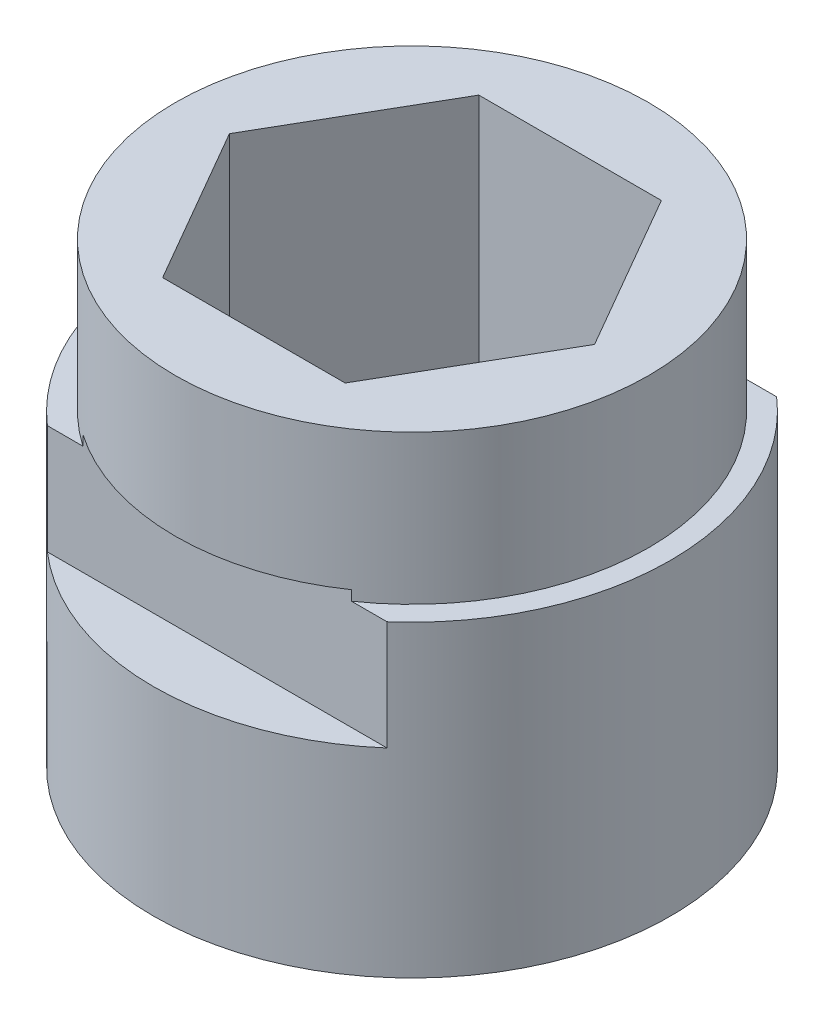
from build123d import *

# Parameters (mm, degrees)
SKETCH1_R               = 7.5565
BOSS_EXTRUDE1_DEPTH     = 13.97
SKETCH2_R               = 7.5565
SKETCH2_R_2             = 3.3
BOSS_EXTRUDE2_DEPTH     = 0.635
SKETCH4_R               = 8.255
SKETCH4_R_2             = 7.5565
BOSS_EXTRUDE3_DEPTH     = 9.8425
SKETCH3_W               = 2.140633032
SKETCH3_H               = 3.81
SKETCH3_W_2             = 2.256055482
CUT_EXTRUDE1_DEPTH      = 9.255
CUT_EXTRUDE1_DEPTH_BACK = 9.255


with BuildPart() as part:
    # Sketch1 → Boss-Extrude1 (new body)
    with BuildSketch(Plane(origin=(0, 0, 0), x_dir=(1, 0, 0), z_dir=(0, 1, 0))):
        Circle(SKETCH1_R)
        Polygon((-2.915618859, 5.05), (-5.831237719, 0), (-2.915618859, -5.05), (2.915618859, -5.05), (5.831237719, 0), (2.915618859, 5.05), align=None, mode=Mode.SUBTRACT)
    extrude(amount=BOSS_EXTRUDE1_DEPTH)

    # Sketch2 → Boss-Extrude2 (add)
    with BuildSketch(Plane.XZ):
        Circle(SKETCH2_R)
        Circle(SKETCH2_R_2, mode=Mode.SUBTRACT)
    extrude(amount=BOSS_EXTRUDE2_DEPTH)

    # Sketch4 → Boss-Extrude3 (add)
    with BuildSketch(Plane.XZ.offset(0.635)):
        Circle(SKETCH4_R)
        Circle(SKETCH4_R_2, mode=Mode.SUBTRACT)
    extrude(amount=-BOSS_EXTRUDE3_DEPTH)

    # Sketch3 → Cut-Extrude1 (cut, two sides)
    with BuildSketch(Plane(origin=(0, 0, 0), x_dir=(0, 0, -1), z_dir=(1, 0, 0))) as cut_extrude1_sk:
        with Locations((-7.293316516, 7.62)):
            Rectangle(SKETCH3_W, SKETCH3_H)
        with Locations((7.351027741, 7.62)):
            Rectangle(SKETCH3_W_2, SKETCH3_H)
    extrude(amount=CUT_EXTRUDE1_DEPTH, mode=Mode.SUBTRACT)
    extrude(cut_extrude1_sk.sketch, amount=-CUT_EXTRUDE1_DEPTH_BACK, mode=Mode.SUBTRACT)


solid = part.part
